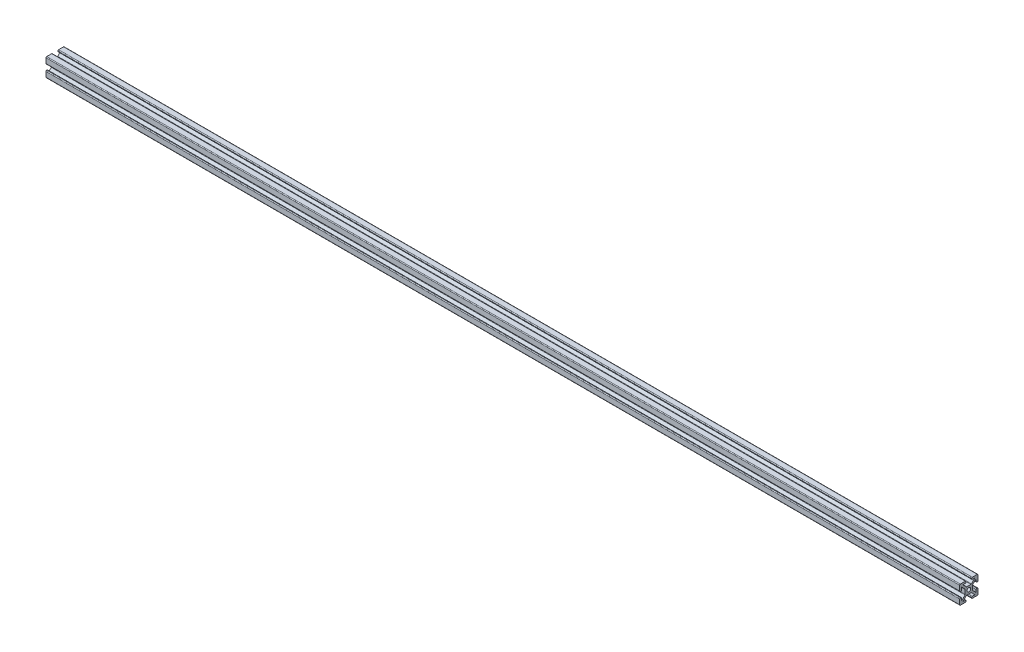
from build123d import *

# Parameters (mm, degrees)
SKETCH1_R           = 2
PROFILE_4X4_1_DEPTH = 1000
SKETCH3_R           = 2.5
CUT_EXTRUDE1_DEPTH  = 10


with BuildPart() as part:
    # Sketch1 → Profile 4X4(1) (new body)
    with BuildSketch(Plane.YZ.offset(-407.600596125)):
        with BuildLine():
            Line((-3, 9.2), (-3, 8.8))
            ThreePointArc((-3, 8.8), (-3.234314575, 8.234314575), (-3.8, 8))
            Line((-3.8, 8), (-6.585786438, 8))
            Line((-6.585786438, 8), (-2.820101013, 4.234314575))
            ThreePointArc((-2.820101013, 4.234314575), (-2.560562334, 4.060896374), (-2.254415588, 4))
            Line((-2.254415588, 4), (2.254415588, 4))
            ThreePointArc((2.254415588, 4), (2.560562334, 4.060896374), (2.820101013, 4.234314575))
            Line((2.820101013, 4.234314575), (6.585786438, 8))
            Line((6.585786438, 8), (3.8, 8))
            ThreePointArc((3.8, 8), (3.234314575, 8.234314575), (3, 8.8))
            Line((3, 8.8), (3, 9.2))
            ThreePointArc((3, 9.2), (3.234314575, 9.765685425), (3.8, 10))
            Line((3.8, 10), (9.2, 10))
            ThreePointArc((9.2, 10), (9.765685425, 9.765685425), (10, 9.2))
            Line((10, 9.2), (10, 3.8))
            ThreePointArc((10, 3.8), (9.765685425, 3.234314575), (9.2, 3))
            Line((9.2, 3), (8.8, 3))
            ThreePointArc((8.8, 3), (8.234314575, 3.234314575), (8, 3.8))
            Line((8, 3.8), (8, 6.585786438))
            Line((8, 6.585786438), (4.234314575, 2.820101013))
            ThreePointArc((4.234314575, 2.820101013), (4.060896374, 2.560562334), (4, 2.254415588))
            Line((4, 2.254415588), (4, -2.254415588))
            ThreePointArc((4, -2.254415588), (4.060896374, -2.560562334), (4.234314575, -2.820101013))
            Line((4.234314575, -2.820101013), (8, -6.585786438))
            Line((8, -6.585786438), (8, -3.8))
            ThreePointArc((8, -3.8), (8.234314575, -3.234314575), (8.8, -3))
            Line((8.8, -3), (9.2, -3))
            ThreePointArc((9.2, -3), (9.765685425, -3.234314575), (10, -3.8))
            Line((10, -3.8), (10, -9.2))
            ThreePointArc((10, -9.2), (9.765685425, -9.765685425), (9.2, -10))
            Line((9.2, -10), (3.8, -10))
            ThreePointArc((3.8, -10), (3.234314575, -9.765685425), (3, -9.2))
            Line((3, -9.2), (3, -8.8))
            ThreePointArc((3, -8.8), (3.234314575, -8.234314575), (3.8, -8))
            Line((3.8, -8), (6.585786438, -8))
            Line((6.585786438, -8), (2.820101013, -4.234314575))
            ThreePointArc((2.820101013, -4.234314575), (2.560562334, -4.060896374), (2.254415588, -4))
            Line((2.254415588, -4), (-2.254415588, -4))
            ThreePointArc((-2.254415588, -4), (-2.560562334, -4.060896374), (-2.820101013, -4.234314575))
            Line((-2.820101013, -4.234314575), (-6.585786438, -8))
            Line((-6.585786438, -8), (-3.8, -8))
            ThreePointArc((-3.8, -8), (-3.234314575, -8.234314575), (-3, -8.8))
            Line((-3, -8.8), (-3, -9.2))
            ThreePointArc((-3, -9.2), (-3.234314575, -9.765685425), (-3.8, -10))
            Line((-3.8, -10), (-9.2, -10))
            ThreePointArc((-9.2, -10), (-9.765685425, -9.765685425), (-10, -9.2))
            Line((-10, -9.2), (-10, -3.8))
            ThreePointArc((-10, -3.8), (-9.765685425, -3.234314575), (-9.2, -3))
            Line((-9.2, -3), (-8.8, -3))
            ThreePointArc((-8.8, -3), (-8.234314575, -3.234314575), (-8, -3.8))
            Line((-8, -3.8), (-8, -6.585786438))
            Line((-8, -6.585786438), (-4.234314575, -2.820101013))
            ThreePointArc((-4.234314575, -2.820101013), (-4.060896374, -2.560562334), (-4, -2.254415588))
            Line((-4, -2.254415588), (-4, 2.254415588))
            ThreePointArc((-4, 2.254415588), (-4.060896374, 2.560562334), (-4.234314575, 2.820101013))
            Line((-4.234314575, 2.820101013), (-8, 6.585786438))
            Line((-8, 6.585786438), (-8, 3.8))
            ThreePointArc((-8, 3.8), (-8.234314575, 3.234314575), (-8.8, 3))
            Line((-8.8, 3), (-9.2, 3))
            ThreePointArc((-9.2, 3), (-9.765685425, 3.234314575), (-10, 3.8))
            Line((-10, 3.8), (-10, 9.2))
            ThreePointArc((-10, 9.2), (-9.765685425, 9.765685425), (-9.2, 10))
            Line((-9.2, 10), (-3.8, 10))
            ThreePointArc((-3.8, 10), (-3.234314575, 9.765685425), (-3, 9.2))
        make_face()
        Circle(SKETCH1_R, mode=Mode.SUBTRACT)
    extrude(amount=PROFILE_4X4_1_DEPTH)

    # Sketch3 → Cut-Extrude1 (cut)
    with BuildSketch(Plane(origin=(0, 4, 0), x_dir=(1, 0, 0), z_dir=(0, 1, 0))):
        with Locations(Location((472.399403875, 0, 0), (0, 0, 295.608789007))):
            Circle(SKETCH3_R)
    extrude(amount=-CUT_EXTRUDE1_DEPTH, mode=Mode.SUBTRACT)


solid = part.part
